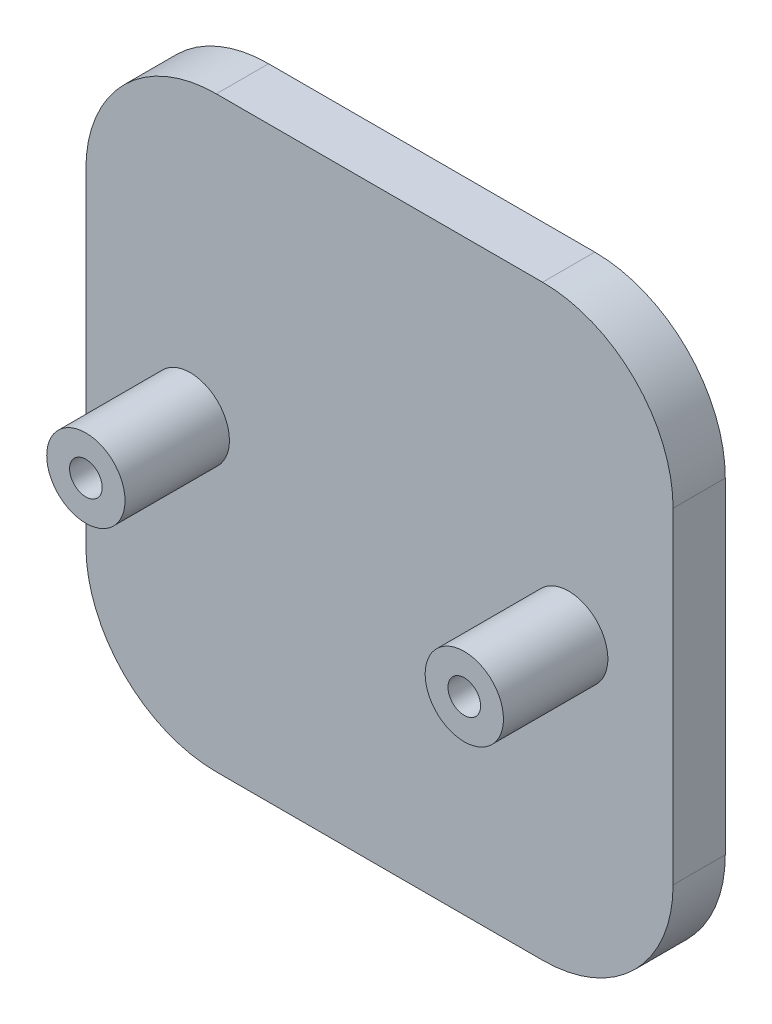
from build123d import *

# Parameters (mm, degrees)
SKETCH5_W                       = 45
SKETCH5_H                       = 45
BOSS_EXTRUDE1_DEPTH             = 4
SKETCH7_R                       = 3
BOSS_EXTRUDE2_DEPTH             = 8
SKETCH9_R                       = 3
BOSS_EXTRUDE3_DEPTH             = 8
TAP_DRILL_FOR_M3X0_5_TAP1_D     = 2.5
TAP_DRILL_FOR_M3X0_5_TAP1_DEPTH = 8
TAP_DRILL_FOR_M3X0_5_TAP1_TIP   = 0.751075774
TAP_DRILL_FOR_M3X0_5_TAP2_D     = 2.5
TAP_DRILL_FOR_M3X0_5_TAP2_DEPTH = 8
TAP_DRILL_FOR_M3X0_5_TAP2_TIP   = 0.751075774
FILLET3_R                       = 10
FILLET4_R                       = 10


with BuildPart() as part:
    # Sketch5 → Boss-Extrude1 (new body)
    with BuildSketch(Plane.XY):
        Rectangle(SKETCH5_W, SKETCH5_H)
    extrude(amount=BOSS_EXTRUDE1_DEPTH)

    # Sketch7 → Boss-Extrude2 (add)
    with BuildSketch(Plane.XY.offset(4)):
        with Locations((-14.5, 0)):
            Circle(SKETCH7_R)
    extrude(amount=BOSS_EXTRUDE2_DEPTH)

    # Sketch9 → Boss-Extrude3 (add)
    with BuildSketch(Plane.XY.offset(4)):
        with Locations((14.5, 0)):
            Circle(SKETCH9_R)
    extrude(amount=BOSS_EXTRUDE3_DEPTH)

    # Tap Drill for M3x0.5 Tap1
    with Locations(Plane.XY.offset(12)):
        with Locations((-14.5, 0)):
            Hole(TAP_DRILL_FOR_M3X0_5_TAP1_D / 2, depth=TAP_DRILL_FOR_M3X0_5_TAP1_DEPTH)
            with Locations((0, 0, -(TAP_DRILL_FOR_M3X0_5_TAP1_DEPTH + TAP_DRILL_FOR_M3X0_5_TAP1_TIP / 2))):  # 118° drill point
                Cone(0, TAP_DRILL_FOR_M3X0_5_TAP1_D / 2, TAP_DRILL_FOR_M3X0_5_TAP1_TIP, mode=Mode.SUBTRACT)

    # Tap Drill for M3x0.5 Tap2
    with Locations(Plane.XY.offset(12)):
        with Locations((14.5, 0)):
            Hole(TAP_DRILL_FOR_M3X0_5_TAP2_D / 2, depth=TAP_DRILL_FOR_M3X0_5_TAP2_DEPTH)
            with Locations((0, 0, -(TAP_DRILL_FOR_M3X0_5_TAP2_DEPTH + TAP_DRILL_FOR_M3X0_5_TAP2_TIP / 2))):  # 118° drill point
                Cone(0, TAP_DRILL_FOR_M3X0_5_TAP2_D / 2, TAP_DRILL_FOR_M3X0_5_TAP2_TIP, mode=Mode.SUBTRACT)

    # Fillet3
    fillet3_edges = [part.edges().sort_by_distance(p)[0] for p in [
        (-22.5, 22.5, 2),
    ]]
    fillet(fillet3_edges, radius=FILLET3_R)

    # Fillet4
    fillet4_edges = [part.edges().sort_by_distance(p)[0] for p in [
        (22.5, -22.5, 2),
        (-22.5, -22.5, 2),
        (22.5, 22.5, 2),
    ]]
    fillet(fillet4_edges, radius=FILLET4_R)


solid = part.part
